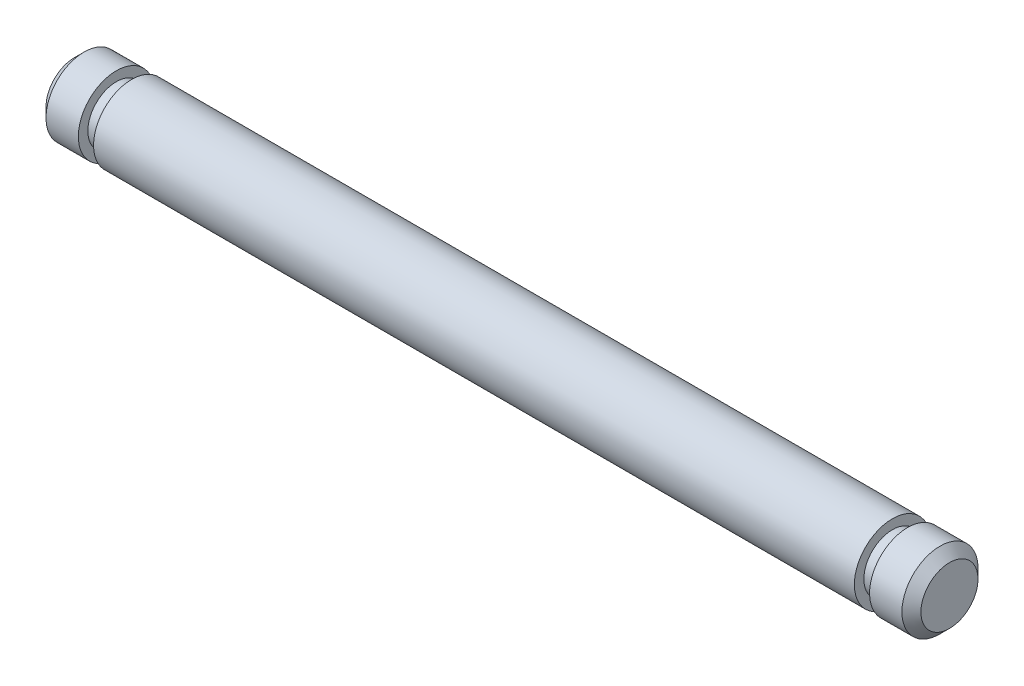
from build123d import *

# Parameters (mm, degrees)
SKETCH1_W          = 46
SKETCH1_H          = 2
CUT_EXTRUDE1_START = -3
SKETCH2_R          = 2
SKETCH2_R_2        = 1.5
CUT_EXTRUDE1_DEPTH = 0.8
CUT_EXTRUDE3_START = -3
SKETCH3_R          = 2
SKETCH3_R_2        = 1.5
CUT_EXTRUDE3_DEPTH = 0.8
CHAMFER1_SIZE      = 0.5


with BuildPart() as part:
    # Sketch1 → Revolve2 (revolve)
    with BuildSketch(Plane.XY):
        with Locations((23, 1)):
            Rectangle(SKETCH1_W, SKETCH1_H)
    revolve(axis=Axis((46, 2, 0), (-1, 0, 0)))

    # Sketch2 → Cut-Extrude1 (cut)
    with BuildSketch(Plane(origin=(46, 0, 0), x_dir=(0, 0, -1), z_dir=(1, 0, 0)).offset(CUT_EXTRUDE1_START)):
        with Locations((0, 2)):
            Circle(SKETCH2_R)
        with Locations((0, 2)):
            Circle(SKETCH2_R_2, mode=Mode.SUBTRACT)
    extrude(amount=CUT_EXTRUDE1_DEPTH, mode=Mode.SUBTRACT)

    # Sketch3 → Cut-Extrude3 (cut)
    with BuildSketch(Plane.ZY.offset(CUT_EXTRUDE3_START)):
        with Locations((0, 2)):
            Circle(SKETCH3_R)
        with Locations((0, 2)):
            Circle(SKETCH3_R_2, mode=Mode.SUBTRACT)
    extrude(amount=CUT_EXTRUDE3_DEPTH, mode=Mode.SUBTRACT)

    # Chamfer1
    chamfer1_edges = [part.edges().sort_by_distance(p)[0] for p in [
        (46, 4, 0),
        (0, 4, 0),
    ]]
    chamfer(chamfer1_edges, length=CHAMFER1_SIZE)


solid = part.part
